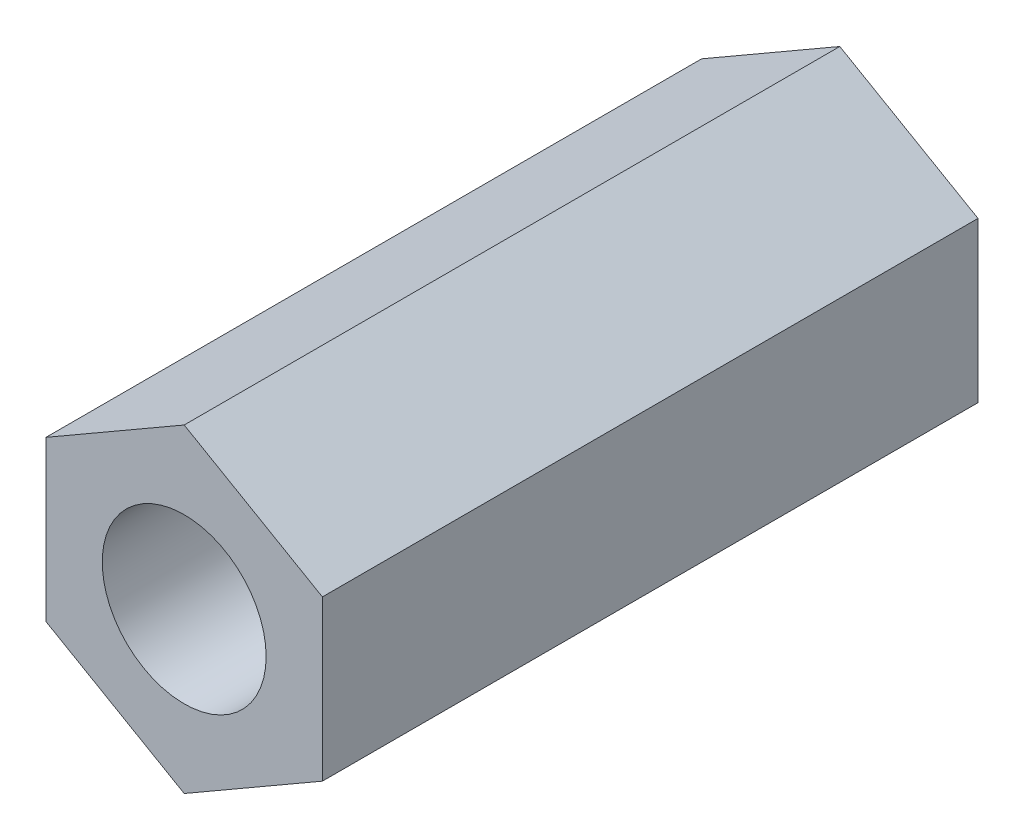
from build123d import *

# Parameters (mm, degrees)
SKETCH1_R           = 1.397
BOSS_EXTRUDE1_DEPTH = 11.176


with BuildPart() as part:
    # Sketch1 → Boss-Extrude1 (new body)
    with BuildSketch(Plane.XY):
        Polygon((-62.801564206, 33.538198737), (-60.445714206, 34.898349368), (-60.445714206, 37.618650632), (-62.801564206, 38.978801263), (-65.157414206, 37.618650632), (-65.157414206, 34.898349368), align=None)
        with Locations((-62.801564206, 36.2585)):
            Circle(SKETCH1_R, mode=Mode.SUBTRACT)
    extrude(amount=BOSS_EXTRUDE1_DEPTH)


solid = part.part
